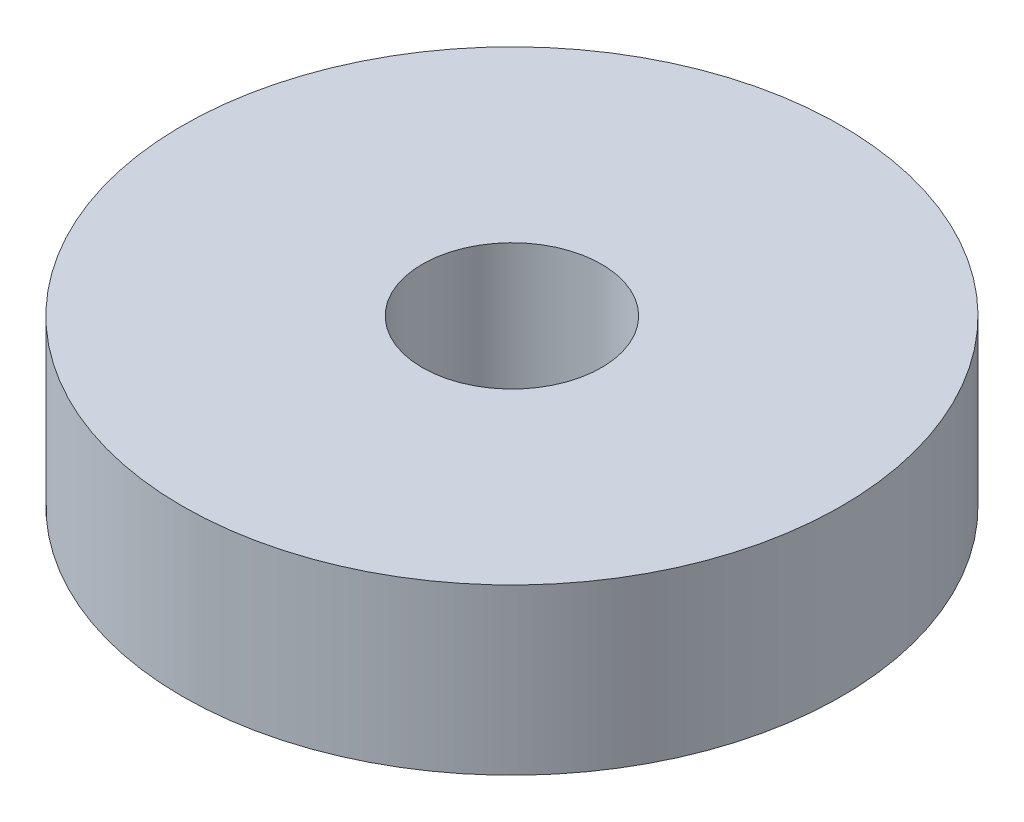
from build123d import *

# Parameters (mm, degrees)
SKETCH1_R             = 6.35
SKETCH1_R_2           = 1.143
BOSS_EXTRUDE1_DEPTH   = 3.175
F_8_32_TAPPED_HOLE1_D = 3.4544


with BuildPart() as part:
    # Sketch1 → Boss-Extrude1 (new body)
    with BuildSketch(Plane(origin=(0, 0, 0), x_dir=(1, 0, 0), z_dir=(0, 1, 0))):
        with Locations(Location((0, 0, 0), (0, 0, 270))):  # turned: the seam where the file's is
            Circle(SKETCH1_R)
        with Locations(Location((0, 0, 0), (0, 0, 270))):  # turned: the seam where the file's is
            Circle(SKETCH1_R_2, mode=Mode.SUBTRACT)
    extrude(amount=BOSS_EXTRUDE1_DEPTH)

    # #8-32 Tapped Hole1 (through all)
    with Locations(Plane(origin=(0, 3.175, 0), x_dir=(1, 0, 0), z_dir=(0, 1, 0))):
        with Locations((0, 0)):
            Hole(F_8_32_TAPPED_HOLE1_D / 2)


solid = part.part
